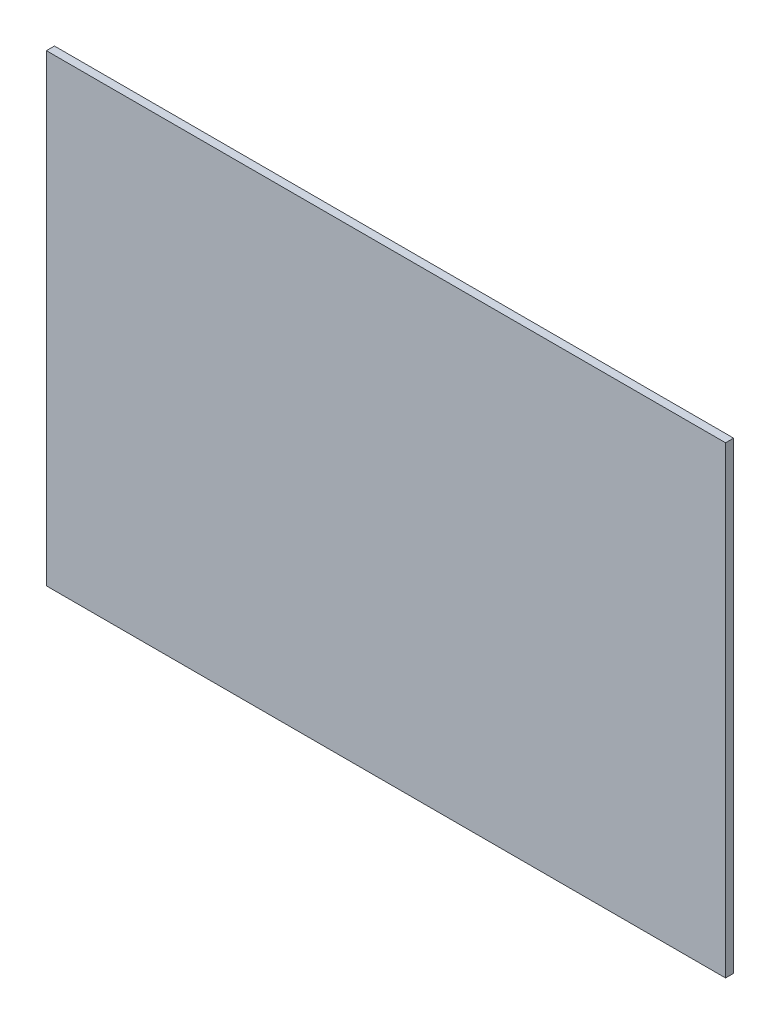
from build123d import *

# Parameters (mm, degrees)
SKETCH1_W           = 337
SKETCH1_H           = 230
BOSS_EXTRUDE1_DEPTH = 4


with BuildPart() as part:
    # Sketch1 → Boss-Extrude1 (new body)
    with BuildSketch(Plane.XY):
        with Locations((168.5, 115)):
            Rectangle(SKETCH1_W, SKETCH1_H)
    extrude(amount=BOSS_EXTRUDE1_DEPTH)


solid = part.part
